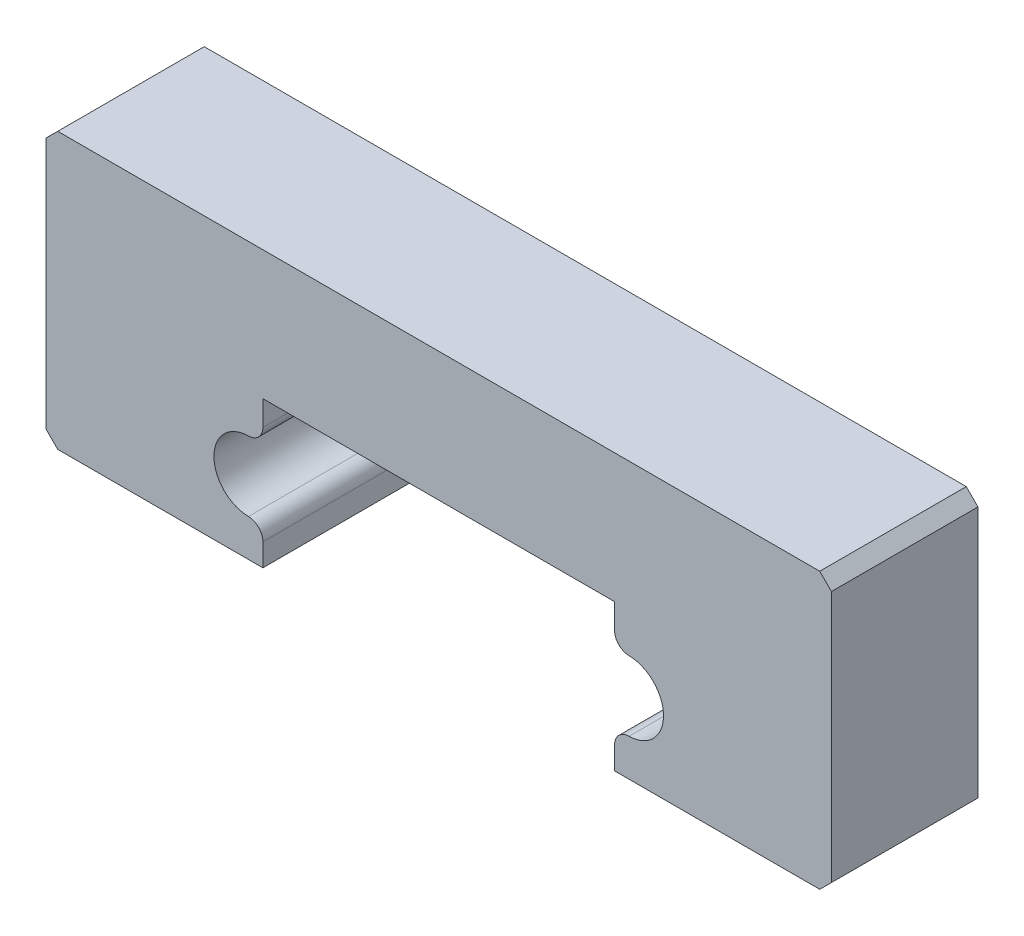
from build123d import *

# Parameters (mm, degrees)
BOSS_EXTRUDE1_DEPTH = 5
FILLET1_R           = 0.5


with BuildPart() as part:
    # Sketch1 → Boss-Extrude1 (new body)
    with BuildSketch(Plane.XY):
        with BuildLine():
            Line((-6, -5), (-13, -5))
            Line((-13, -5), (-13.4, -4.6))
            Line((-13.4, -4.6), (-13.4, 4))
            Line((-13.4, 4), (-13, 4.4))
            Line((-13, 4.4), (13, 4.4))
            Line((13, 4.4), (13.4, 4))
            Line((13.4, 4), (13.4, -4.6))
            Line((13.4, -4.6), (13, -5))
            Line((13, -5), (6, -5))
            Line((6, -5), (6, -3.628898526))
            ThreePointArc((6, -3.628898526), (7.67, -2.54), (6, -1.451101474))
            Line((6, -1.451101474), (6, 0))
            Line((6, 0), (-6, 0))
            Line((-6, 0), (-6, -1.451101474))
            ThreePointArc((-6, -1.451101474), (-7.67, -2.54), (-6, -3.628898526))
            Line((-6, -3.628898526), (-6, -5))
        make_face()
    extrude(amount=BOSS_EXTRUDE1_DEPTH)

    # Fillet1
    fillet1_edges = [part.edges().sort_by_distance(p)[0] for p in [
        (6, -3.628898526, 2.5),
        (6, -1.451101474, 2.5),
        (-6, -1.451101474, 2.5),
        (-6, -3.628898526, 2.5),
    ]]
    fillet(fillet1_edges, radius=FILLET1_R)


solid = part.part
